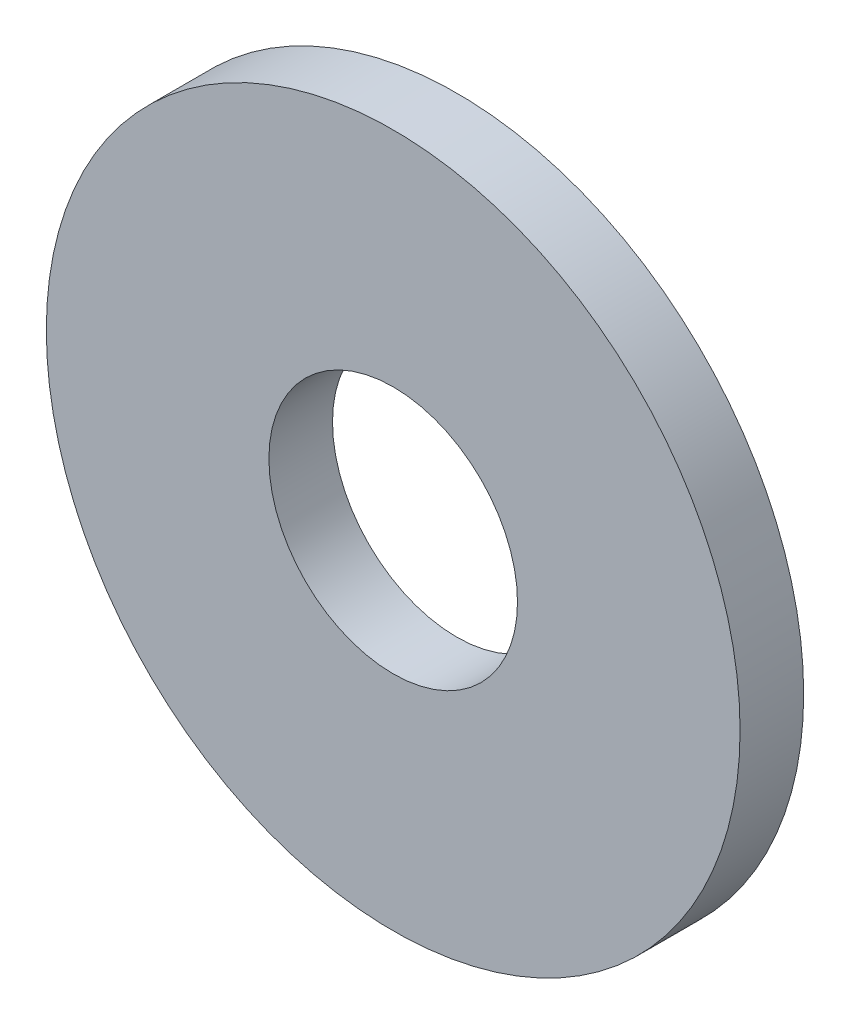
from build123d import *

# Parameters (mm, degrees)
SKETCH1_R           = 6
SKETCH1_R_2         = 2.15
BOSS_EXTRUDE1_DEPTH = 1.1


with BuildPart() as part:
    # Sketch1 → Boss-Extrude1 (new body)
    with BuildSketch(Plane.XY):
        Circle(SKETCH1_R)
        Circle(SKETCH1_R_2, mode=Mode.SUBTRACT)
    extrude(amount=BOSS_EXTRUDE1_DEPTH)


solid = part.part
